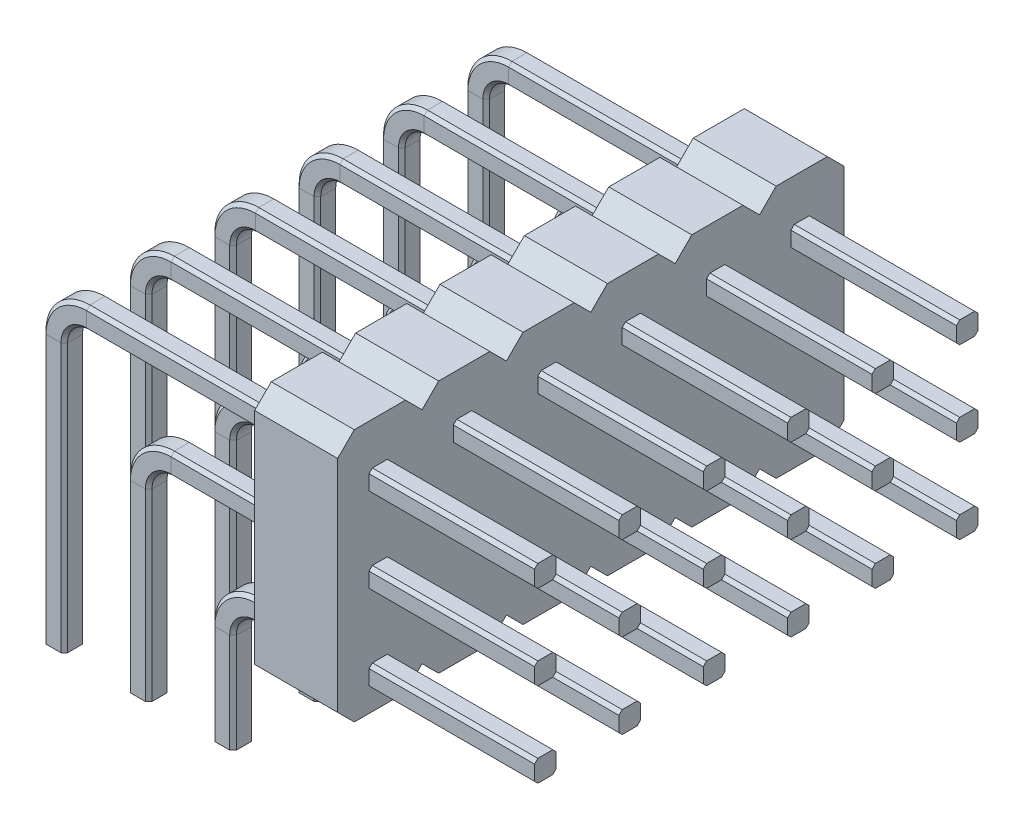
from build123d import *

# Parameters (mm, degrees)
BOSS_EXTRUDE1_DEPTH = 2.5
LPATTERN1_COUNT     = 6
LPATTERN1_PITCH     = 2.54


with BuildPart() as part:
    # Sweep1: sweep along a path in Sketch2
    with BuildLine(Plane.XY) as sweep1_path:
        Line((5.08, 0), (5.08, 3))
        ThreePointArc((5.08, 3), (5.372893219, 3.707106781), (6.08, 4))
        Line((6.08, 4), (14.48, 4))
    # Sketch1 → Sweep1 (sweep)
    with BuildSketch(Plane(origin=(0, 0, 0), x_dir=(1, 0, 0), z_dir=(0, 1, 0))):
        Polygon((5.305, -0.325), (5.405, -0.225), (5.405, 0.225), (5.305, 0.325), (4.855, 0.325), (4.755, 0.225), (4.755, -0.225), (4.855, -0.325), align=None)
    sweep(path=sweep1_path.line)



with BuildPart() as body_2:
    # Sweep2: sweep along a path in Sketch2_3
    with BuildLine(Plane.XY) as sweep2_path:
        Line((2.54, 0), (2.54, 5.54))
        ThreePointArc((2.54, 5.54), (2.832893219, 6.247106781), (3.54, 6.54))
        Line((3.54, 6.54), (14.48, 6.54))
    # Sketch1_3 → Sweep2 (sweep)
    with BuildSketch(Plane(origin=(0, 0, 0), x_dir=(1, 0, 0), z_dir=(0, 1, 0))):
        Polygon((2.765, -0.325), (2.865, -0.225), (2.865, 0.225), (2.765, 0.325), (2.315, 0.325), (2.215, 0.225), (2.215, -0.225), (2.315, -0.325), align=None)
    sweep(path=sweep2_path.line)


with BuildPart() as body_3:
    # Sweep3: sweep along a path in Sketch2_4
    with BuildLine(Plane.XY) as sweep3_path:
        Line((0, 0), (0, 8.08))
        ThreePointArc((0, 8.08), (0.292893219, 8.787106781), (1, 9.08))
        Line((1, 9.08), (14.48, 9.08))
    # Sketch1_4 → Sweep3 (sweep)
    with BuildSketch(Plane(origin=(0, 0, 0), x_dir=(1, 0, 0), z_dir=(0, 1, 0))):
        Polygon((-0.325, 0.225), (-0.225, 0.325), (0.225, 0.325), (0.325, 0.225), (0.325, -0.225), (0.225, -0.325), (-0.225, -0.325), (-0.325, -0.225), align=None)
    sweep(path=sweep3_path.line)


with BuildPart() as part_1:
    add(part.part)

    add(body_2.part)  # Boss-Extrude1 merges body 2

    add(body_3.part)  # Boss-Extrude1 merges body 3
    # Sketch4 → Boss-Extrude1 (add)
    with BuildSketch(Plane.ZY.offset(-7)):
        Polygon((-0.77, 3.055), (0.77, 3.055), (1.27, 3.555), (1.27, 10.175), (0.77, 10.675), (-0.77, 10.675), (-1.27, 10.175), (-1.27, 3.555), align=None)
    extrude(amount=-BOSS_EXTRUDE1_DEPTH)


with BuildPart() as lpattern1_1:
    # LPattern1: pattern copy
    add(part_1.part.moved(Location(Vector(0, 0, -1) * (1 * LPATTERN1_PITCH))))


with BuildPart() as lpattern1_2:
    # LPattern1: pattern copy
    add(part_1.part.moved(Location(Vector(0, 0, -1) * (2 * LPATTERN1_PITCH))))


with BuildPart() as lpattern1_3:
    # LPattern1: pattern copy
    add(part_1.part.moved(Location(Vector(0, 0, -1) * (3 * LPATTERN1_PITCH))))


with BuildPart() as lpattern1_4:
    # LPattern1: pattern copy
    add(part_1.part.moved(Location(Vector(0, 0, -1) * (4 * LPATTERN1_PITCH))))


with BuildPart() as lpattern1_5:
    # LPattern1: pattern copy
    add(part_1.part.moved(Location(Vector(0, 0, -1) * (5 * LPATTERN1_PITCH))))


with BuildPart() as part_2:
    add(part_1.part)

    # Combine1: union LPattern1_1, LPattern1_2, LPattern1_3, LPattern1_4, LPattern1_5
    add(lpattern1_1.part)
    add(lpattern1_2.part)
    add(lpattern1_3.part)
    add(lpattern1_4.part)
    add(lpattern1_5.part)


solid = part_2.part
